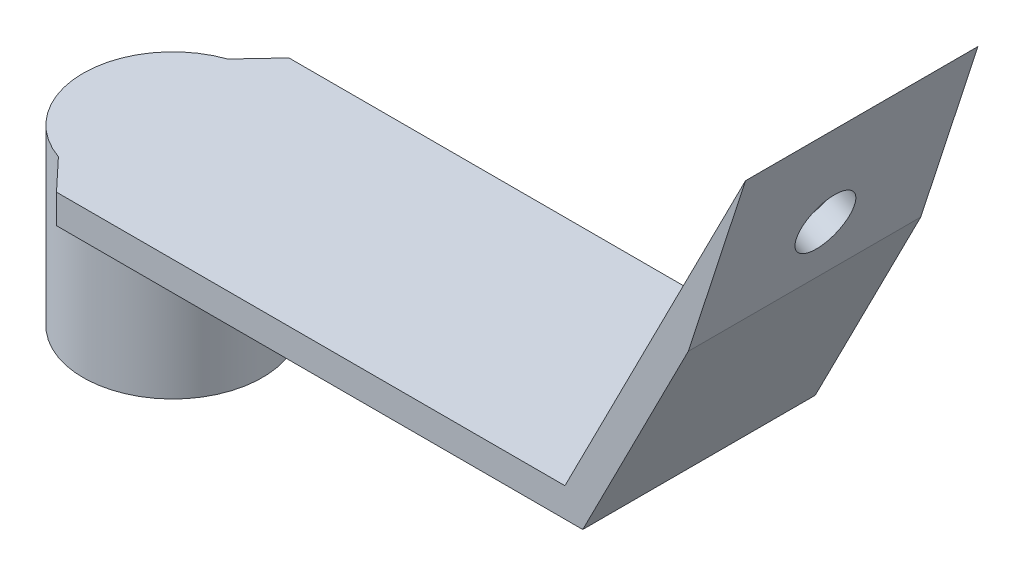
from build123d import *

# Parameters (mm, degrees)
BOSS_EXTRUDE1_DEPTH = 25.4
SKETCH2_R           = 9.801448676
SKETCH2_R_2         = 7.071368029
BOSS_EXTRUDE2_DEPTH = 19
BOSS_EXTRUDE3_DEPTH = 3.175
SKETCH4_R           = 3.175
CUT_EXTRUDE1_DEPTH  = 3.175


with BuildPart() as part:
    # Sketch1 → Boss-Extrude1 (new body)
    with BuildSketch(Plane.XY):
        Polygon((-76.495819173, -3.422180745), (-20.941461675, -3.422180745), (-1.20885062, 35.305249012), (-7.464460479, 16.03438497), (-18.995819173, -6.597180745), (-76.495819173, -6.597180745), align=None)
    extrude(amount=BOSS_EXTRUDE1_DEPTH)

    # Sketch2 → Boss-Extrude2 (add)
    with BuildSketch(Plane(origin=(0, -3.422180745, 0), x_dir=(1, 0, 0), z_dir=(0, 1, 0))):
        with Locations((-76.495819173, -12.7)):
            Circle(SKETCH2_R)
        with Locations((-76.495819173, -12.7)):
            Circle(SKETCH2_R_2, mode=Mode.SUBTRACT)
    extrude(amount=-BOSS_EXTRUDE2_DEPTH)

    # Sketch3 → Boss-Extrude3 (add)
    with BuildSketch(Plane(origin=(0, -3.422180745, 0), x_dir=(1, 0, 0), z_dir=(0, 1, 0))):
        Polygon((-76.495819173, -25.4), (-76.495819173, 0), (-85.929582176, -10.040580563), (-85.929582176, -15.359419437), align=None)
        Polygon((-85.929582176, -15.359419437), (-85.929582176, -10.040580563), (-86.297267848, -12.7), align=None)
    extrude(amount=-BOSS_EXTRUDE3_DEPTH)

    # Sketch4 → Cut-Extrude1 (cut)
    with BuildSketch(Plane(origin=(-15.240970814, 7.765662505, 0), x_dir=(0, 0, 1), z_dir=(-0.891006524, 0.4539905, 0))):
        with Locations((12.7, 18.20840051)):
            Circle(SKETCH4_R)
    extrude(amount=-CUT_EXTRUDE1_DEPTH, mode=Mode.SUBTRACT)


solid = part.part
